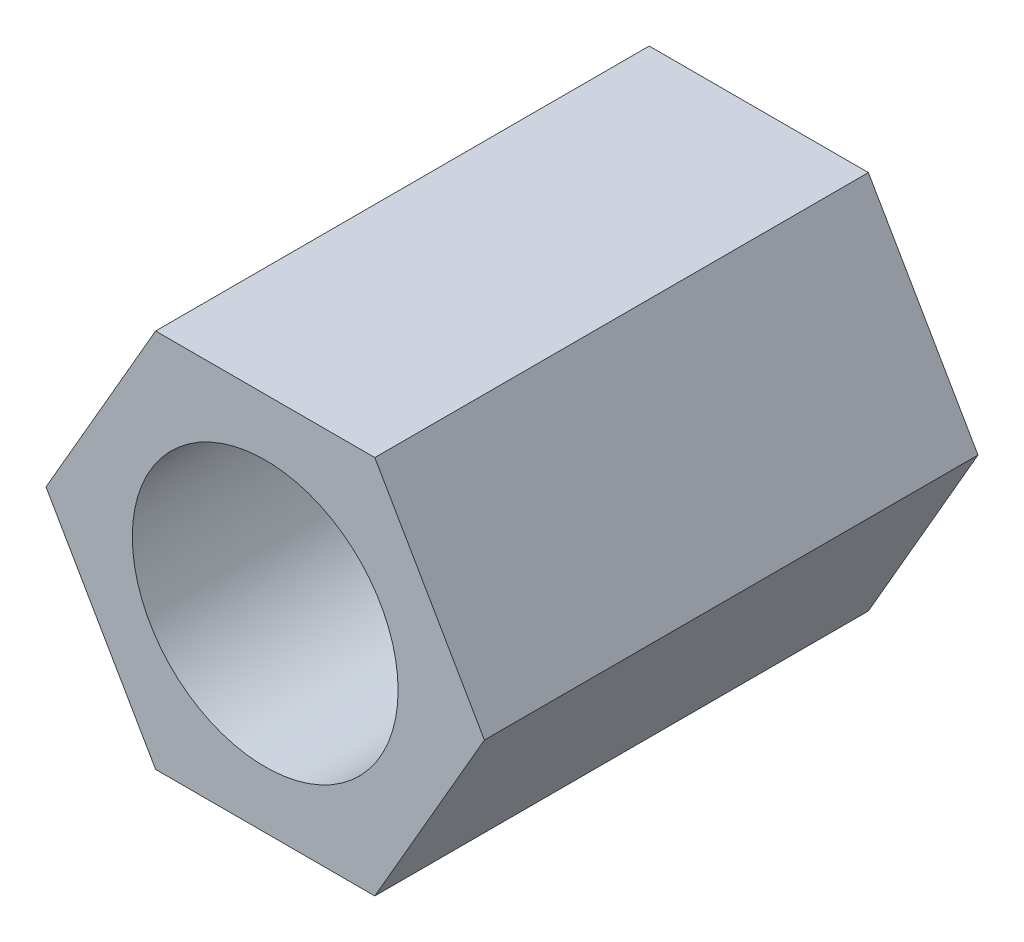
from build123d import *

# Parameters (mm, degrees)
ESTRUSIONE_ESTRUSIONE1_DEPTH = 6.5
SCHIZZO2_R                   = 1.75
TAGLIO_ESTRUSIONE1_DEPTH     = 15


with BuildPart() as part:
    # Schizzo1 → Estrusione-Estrusione1 (new body)
    with BuildSketch(Plane.XY):
        Polygon((1.443375673, 2.5), (-1.443375673, 2.5), (-2.886751346, 0), (-1.443375673, -2.5), (1.443375673, -2.5), (2.886751346, 0), align=None)
    extrude(amount=ESTRUSIONE_ESTRUSIONE1_DEPTH)

    # Schizzo2 → Taglio-Estrusione1 (cut)
    with BuildSketch(Plane.XY.offset(6.5)):
        Circle(SCHIZZO2_R)
    extrude(amount=-TAGLIO_ESTRUSIONE1_DEPTH, mode=Mode.SUBTRACT)


solid = part.part
